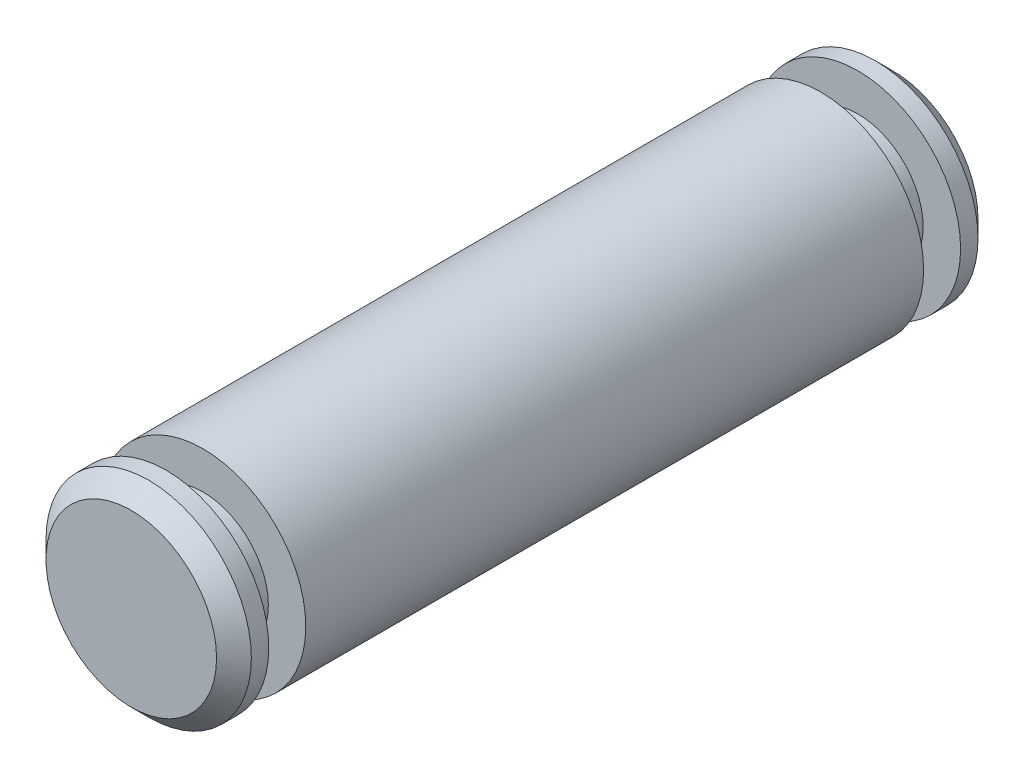
from build123d import *

# Parameters (mm, degrees)
SKETCH1_R           = 1.4986
BOSS_EXTRUDE1_DEPTH = 5.55625
SKETCH2_W           = 0.54
SKETCH2_H           = 0.5461
CHAMFER1_SIZE       = 0.254


with BuildPart() as part:
    # Sketch1 → Boss-Extrude1 (new body, symmetric)
    with BuildSketch(Plane.XY):
        Circle(SKETCH1_R)
    extrude(amount=BOSS_EXTRUDE1_DEPTH, both=True)

    # Sketch2 → Cut-Revolve1 (revolve, cut)
    with BuildSketch(Plane(origin=(0, 0, 0), x_dir=(0, 0, -1), z_dir=(1, 0, 0))):
        with Locations((-4.77825, -1.22555)):
            Rectangle(SKETCH2_W, SKETCH2_H)
        with Locations((4.77825, -1.22555)):
            Rectangle(SKETCH2_W, SKETCH2_H)
    revolve(axis=Axis((0, 0, 8.828032455), (0, 0, -1)), mode=Mode.SUBTRACT)

    # Chamfer1
    chamfer1_edges = [part.edges().sort_by_distance(p)[0] for p in [
        (-1.4986, 0, -5.55625),
        (-1.4986, 0, 5.55625),
    ]]
    chamfer(chamfer1_edges, length=CHAMFER1_SIZE)


solid = part.part
